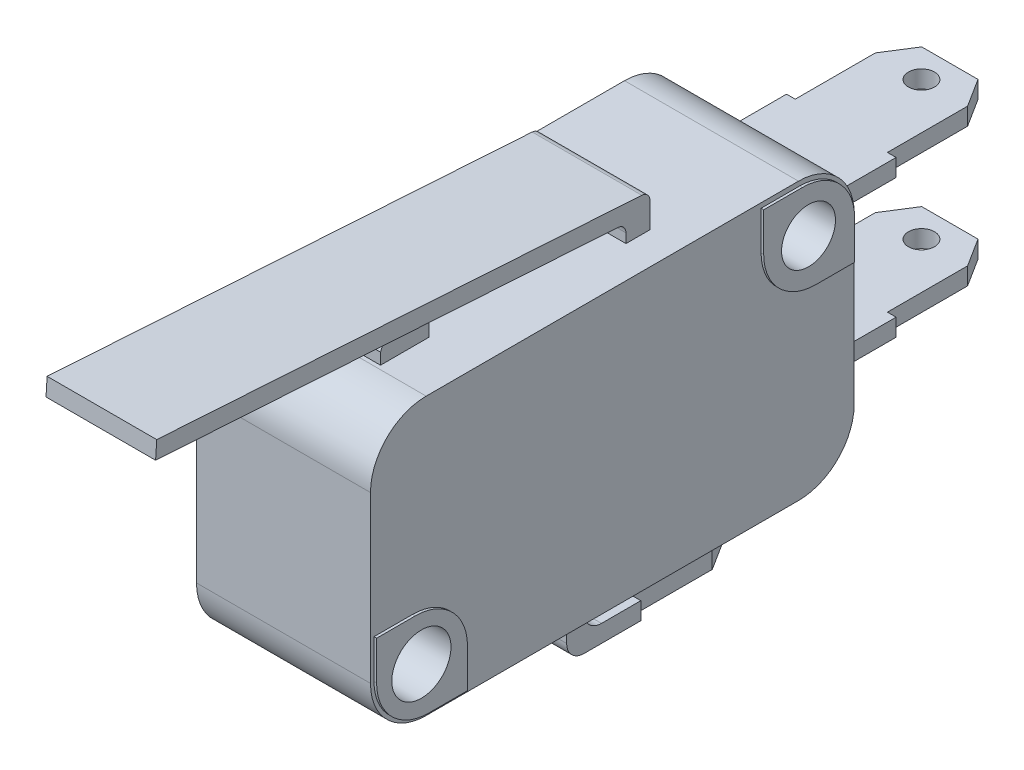
from build123d import *

# Parameters (mm, degrees)
BLOCOBASE_DEPTH           = 5
SKFIXACAO_R               = 1.7
SKFIXACAO_R_2             = 1.55
FIXACAO_DEPTH             = 5.15
RESSALTOFIXACAO_DEPTH     = 0.15
BOTAO_DEPTH               = 2.15
SKETCH5_W                 = 6.3
SKETCH5_H                 = 1
BASECONECTORNONC_DEPTH    = 10.5
SKDESENHOCONECTORNONC_R   = 0.75
DESENHOCONECTORNONC_DEPTH = 20.5
BASECONECTORCOM_DEPTH     = 3.15
SKDESENHOCONECTORCOM_R    = 0.75
DESENHOCONECTORCOM_DEPTH  = 1
BASECONTATO_DEPTH         = 3.15
SKAPOIOROLO_R             = 0.7
APOIOROLO_DEPTH           = 1
SKROLO_R                  = 2.5
ROLO_DEPTH                = 4.3
SKETCH6_W                 = 15.037683952
SKETCH6_H                 = 10.848275608
CUT_EXTRUDE1_DEPTH        = 10
SKETCH7_W                 = 6.3
SKETCH7_H                 = 1
BOSS_EXTRUDE1_DEPTH       = 0.001


with BuildPart() as part:
    # skBlocoBase → BlocoBase (new body, symmetric)
    with BuildSketch(Plane(origin=(0, 0, 0), x_dir=(0, 0, -1), z_dir=(1, 0, 0))):
        with BuildLine():
            Line((-10.7, 7.95), (10.7, 7.95))
            ThreePointArc((10.7, 7.95), (12.9627417, 7.0127417), (13.9, 4.75))
            Line((13.9, 4.75), (13.9, -4.75))
            ThreePointArc((13.9, -4.75), (12.9627417, -7.0127417), (10.7, -7.95))
            Line((10.7, -7.95), (-10.7, -7.95))
            ThreePointArc((-10.7, -7.95), (-12.9627417, -7.0127417), (-13.9, -4.75))
            Line((-13.9, -4.75), (-13.9, 4.75))
            ThreePointArc((-13.9, 4.75), (-12.9627417, 7.0127417), (-10.7, 7.95))
        make_face()
    extrude(amount=BLOCOBASE_DEPTH, both=True)

    # skFixacao → Fixacao (cut, symmetric)
    with BuildSketch(Plane(origin=(0, 0, 0), x_dir=(0, 0, -1), z_dir=(1, 0, 0))):
        with Locations((-11.125, -5.1)):
            Circle(SKFIXACAO_R)
        with Locations((11.125, 5.1)):
            Circle(SKFIXACAO_R_2)
    extrude(amount=FIXACAO_DEPTH, both=True, mode=Mode.SUBTRACT)

    # skRessaltoFixacao → RessaltoFixacao (add)
    with BuildSketch(Plane(origin=(5, 0, 0), x_dir=(0, 0, -1), z_dir=(1, 0, 0))):
        with BuildLine():
            ThreePointArc((-8.475, -5.525), (-9.353679656, -3.403679656), (-11.475, -2.525))
            Line((-11.475, -2.525), (-13.7, -2.525))
            Line((-13.7, -2.525), (-13.7, -4.75))
            ThreePointArc((-13.7, -4.75), (-12.821320344, -6.871320344), (-10.7, -7.75))
            Line((-10.7, -7.75), (-8.475, -7.75))
            Line((-8.475, -7.75), (-8.475, -5.525))
        make_face()
        with BuildLine():
            ThreePointArc((-9.789845005, -6.152312282), (-10.474438165, -6.670595205), (-11.325, -6.788194302))
            ThreePointArc((-11.325, -6.788194302), (-11.775561835, -3.529404795), (-9.789845005, -6.152312282))
        make_face(mode=Mode.SUBTRACT)
        with BuildLine():
            ThreePointArc((13.775, 4.675), (12.896320344, 6.796320344), (10.775, 7.675))
            Line((10.775, 7.675), (8.55, 7.675))
            Line((8.55, 7.675), (8.55, 5.45))
            ThreePointArc((8.55, 5.45), (9.428679656, 3.328679656), (11.55, 2.45))
            Line((11.55, 2.45), (13.775, 2.45))
            Line((13.775, 2.45), (13.775, 4.675))
        make_face()
        with BuildLine():
            ThreePointArc((12.353274612, 4.1545681), (11.71815932, 3.667986725), (10.925, 3.562957385))
            ThreePointArc((10.925, 3.562957385), (10.53184068, 6.532013275), (12.353274612, 4.1545681))
        make_face(mode=Mode.SUBTRACT)
    ressaltofixacao = extrude(amount=RESSALTOFIXACAO_DEPTH)

    # MirrorRessaltoFixacao: RessaltoFixacao across plane
    add(ressaltofixacao.mirror(Plane(origin=(0, 0, 0), x_dir=(0, 0, 1), z_dir=(1, 0, 0))))

    # skBotao → Botao (add, symmetric)
    with BuildSketch(Plane(origin=(0, 0, 0), x_dir=(0, 0, -1), z_dir=(1, 0, 0))):
        with BuildLine():
            Line((-10.475, 7.95), (-10.475, 8.6))
            ThreePointArc((-10.475, 8.6), (-9.075, 9.6), (-7.675, 8.6))
            Line((-7.675, 8.6), (-7.675, 7.95))
            Line((-7.675, 7.95), (-10.475, 7.95))
        make_face()
    extrude(amount=BOTAO_DEPTH, both=True)

    # Sketch5 → BaseConectorNONC (add)
    with BuildSketch(Plane(origin=(0, 0, -13.9), x_dir=(-1, 0, 0), z_dir=(0, 0, -1))):
        with Locations((0, -3.975)):
            Rectangle(SKETCH5_W, SKETCH5_H)
        with Locations((0, 3.975)):
            Rectangle(SKETCH5_W, SKETCH5_H)
    extrude(amount=BASECONECTORNONC_DEPTH)

    # skDesenhoConectorNONC → DesenhoConectorNONC (cut)
    with BuildSketch(Plane.XZ.offset(4.475)):
        Polygon((2.65, -22.767142952), (1.616967042, -24.4), (3.15, -24.4), (3.15, -18.161236833), (2.65, -18.161236833), align=None)
        Polygon((-3.15, -24.4), (-1.616967042, -24.4), (-2.65, -22.767142952), (-2.65, -18.161236833), (-3.15, -18.161236833), align=None)
        with Locations((0, -22.767142952)):
            Circle(SKDESENHOCONECTORNONC_R)
    extrude(amount=-DESENHOCONECTORNONC_DEPTH, mode=Mode.SUBTRACT)

    # skBaseConectorCOM → BaseConectorCOM (add, symmetric)
    with BuildSketch(Plane(origin=(0, 0, 0), x_dir=(0, 0, -1), z_dir=(1, 0, 0))):
        with BuildLine():
            Line((9.725, -11.25), (0.225, -11.25))
            ThreePointArc((0.225, -11.25), (-0.482106781, -10.957106781), (-0.775, -10.25))
            Line((-0.775, -10.25), (-0.775, -7.95))
            Line((-0.775, -7.95), (0.225, -7.95))
            Line((0.225, -7.95), (0.225, -9.25))
            ThreePointArc((0.225, -9.25), (0.517893219, -9.957106781), (1.225, -10.25))
            Line((1.225, -10.25), (9.725, -10.25))
            Line((9.725, -10.25), (9.725, -11.25))
        make_face()
    extrude(amount=BASECONECTORCOM_DEPTH, both=True)

    # skDesenhoConectorCOM → DesenhoConectorCOM (cut)
    with BuildSketch(Plane.XZ.offset(11.25)):
        Polygon((2.65, -8.092142952), (1.616967042, -9.725), (3.15, -9.725), (3.15, -3.486236833), (2.65, -3.486236833), align=None)
        Polygon((-3.15, -9.725), (-1.616967042, -9.725), (-2.65, -8.092142952), (-2.65, -3.486236833), (-3.15, -3.486236833), align=None)
        with Locations((0, -8.092142952)):
            Circle(SKDESENHOCONECTORCOM_R)
    extrude(amount=-DESENHOCONECTORCOM_DEPTH, mode=Mode.SUBTRACT)

    # skBaseContato → BaseContato (add, symmetric)
    with BuildSketch(Plane(origin=(0, 0, 0), x_dir=(0, 0, -1), z_dir=(1, 0, 0))):
        with BuildLine():
            Line((2.63302332, 7.95), (2.63302332, 8.486635004))
            ThreePointArc((2.63302332, 8.486635004), (2.497665983, 8.828739854), (2.164880406, 8.985619098))
            Line((2.164880406, 8.985619098), (-24.4, 10.681624431))
            Line((-24.4, 10.681624431), (-24.336285828, 11.679592619))
            Line((-24.336285828, 11.679592619), (3.545575005, 9.899506131))
            ThreePointArc((3.545575005, 9.899506131), (3.878360582, 9.742626887), (4.013717919, 9.400522037))
            Line((4.013717919, 9.400522037), (4.013717919, 7.95))
            Line((4.013717919, 7.95), (2.63302332, 7.95))
        make_face()
    extrude(amount=BASECONTATO_DEPTH, both=True)

    # skApoioRolo → ApoioRolo (add)
    with BuildSketch(Plane(origin=(3.15, 0, 0), x_dir=(0, 0, -1), z_dir=(1, 0, 0))):
        with BuildLine():
            ThreePointArc((-21.354211514, 14.486814776), (-22.754211514, 15.886814776), (-24.154211514, 14.486814776))
            Line((-24.154211514, 14.486814776), (-24.336285828, 11.679592619))
            Line((-24.336285828, 11.679592619), (-22.939130364, 11.590392778))
            Line((-22.939130364, 11.590392778), (-21.541974901, 11.501192936))
            Line((-21.541974901, 11.501192936), (-21.365242034, 14.3114187))
            Line((-21.365242034, 14.3114187), (-21.354211514, 14.486814776))
        make_face()
        with Locations((-22.754211514, 14.486814776)):
            Circle(SKAPOIOROLO_R, mode=Mode.SUBTRACT)
    apoiorolo = extrude(amount=-APOIOROLO_DEPTH)

    # MirrorApoioRolo: ApoioRolo across plane
    add(apoiorolo.mirror(Plane(origin=(0, 0, 0), x_dir=(0, 0, 1), z_dir=(1, 0, 0))))

    # skRolo → Rolo (add)
    with BuildSketch(Plane.ZY.offset(-2.15)):
        with Locations((22.754211514, 14.486814776)):
            Circle(SKROLO_R)
    extrude(amount=ROLO_DEPTH)

    # Sketch6 → Cut-Extrude1 (cut)
    with BuildSketch(Plane(origin=(0, 10.084763511, -0.643850544), x_dir=(1, 0, 0), z_dir=(0, 0.997968188, -0.063714172))):
        with Locations((-4.368841976, -23.671158356)):
            Rectangle(SKETCH6_W, SKETCH6_H)
    extrude(amount=CUT_EXTRUDE1_DEPTH, mode=Mode.SUBTRACT)

    # Sketch7 → Boss-Extrude1 (add)
    with BuildSketch(Plane(origin=(0, 1.594829108, 24.980136372), x_dir=(1, 0, 0), z_dir=(0, 0.063714172, 0.997968188))):
        with Locations((0, 9.605295572)):
            Rectangle(SKETCH7_W, SKETCH7_H)
    extrude(amount=BOSS_EXTRUDE1_DEPTH)


solid = part.part
